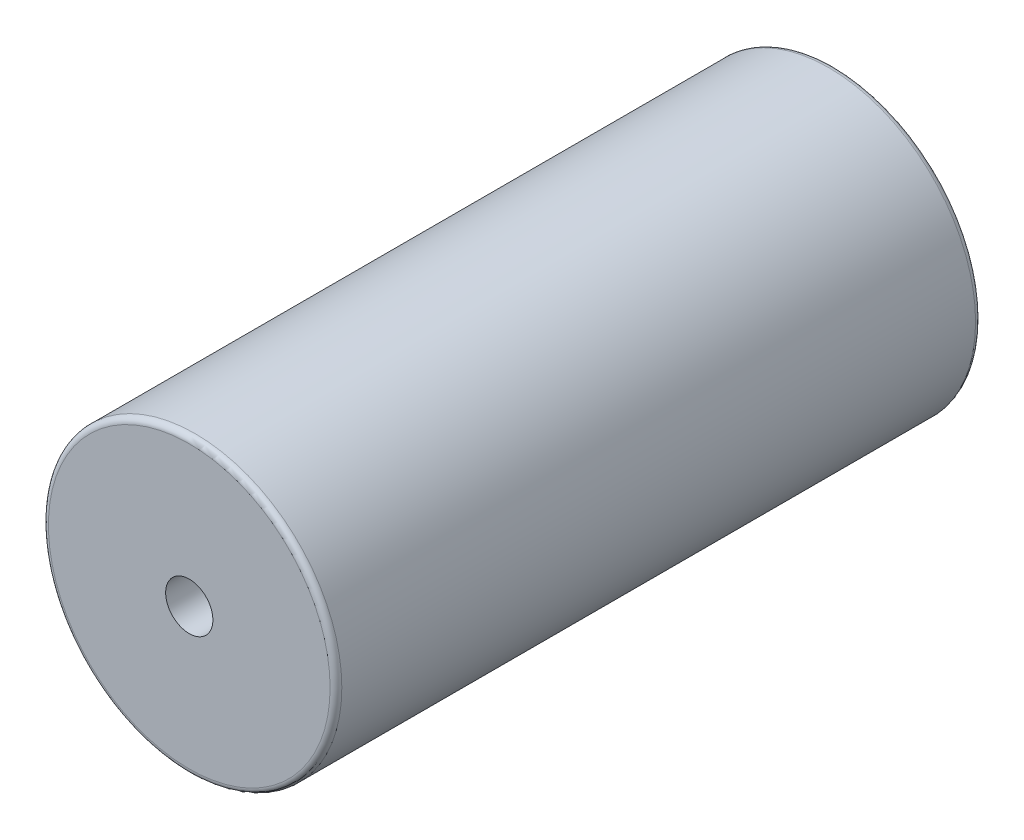
from build123d import *

# Parameters (mm, degrees)
SKIZZE1_R                       = 25
SKIZZE1_R_2                     = 4.025
AUFSATZ_LINEAR_AUSTRAGEN1_DEPTH = 110
VERRUNDUNG1_R                   = 1


with BuildPart() as part:
    # Skizze1 → Aufsatz-Linear austragen1 (new body)
    with BuildSketch(Plane.XY):
        Circle(SKIZZE1_R)
        Circle(SKIZZE1_R_2, mode=Mode.SUBTRACT)
    extrude(amount=AUFSATZ_LINEAR_AUSTRAGEN1_DEPTH)

    # Verrundung1
    verrundung1_edges = [part.edges().sort_by_distance(p)[0] for p in [
        (-25, 0, 0),
        (-25, 0, 110),
    ]]
    fillet(verrundung1_edges, radius=VERRUNDUNG1_R)


solid = part.part
